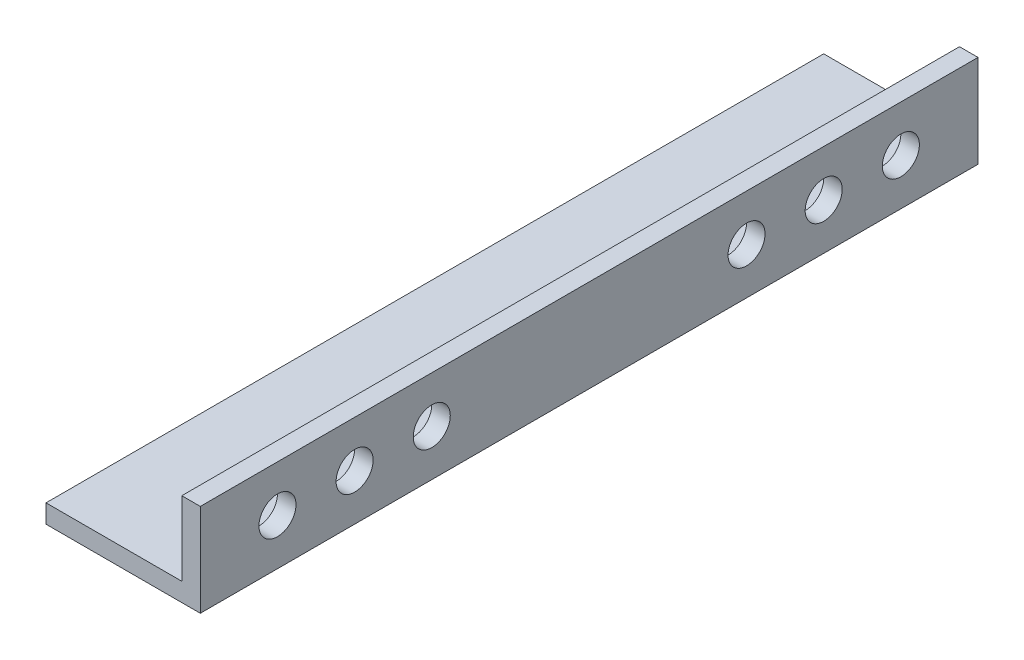
from build123d import *

# Parameters (mm, degrees)
SALIENTE_EXTRUIR1_DEPTH = 126
CROQUIS2_R              = 3
CORTAR_EXTRUIR3_DEPTH   = 63


with BuildPart() as part:
    # Croquis1 → Saliente-Extruir1 (new body)
    with BuildSketch(Plane.XY):
        Polygon((0, 0), (3, 0), (3, -15), (-22, -15), (-22, -12), (0, -12), align=None)
    extrude(amount=SALIENTE_EXTRUIR1_DEPTH)

    # Croquis2 → Cortar-Extruir3 (cut, symmetric)
    with BuildSketch(Plane(origin=(3, 0, 0), x_dir=(0, 0, -1), z_dir=(1, 0, 0))):
        with Locations((-113.5, -7.5)):
            Circle(CROQUIS2_R)
        with Locations((-101, -7.5)):
            Circle(CROQUIS2_R)
        with Locations((-88.5, -7.5)):
            Circle(CROQUIS2_R)
        with Locations((-12.5, -7.5)):
            Circle(CROQUIS2_R)
        with Locations((-25, -7.5)):
            Circle(CROQUIS2_R)
        with Locations((-37.5, -7.5)):
            Circle(CROQUIS2_R)
    extrude(amount=CORTAR_EXTRUIR3_DEPTH, both=True, mode=Mode.SUBTRACT)


solid = part.part
